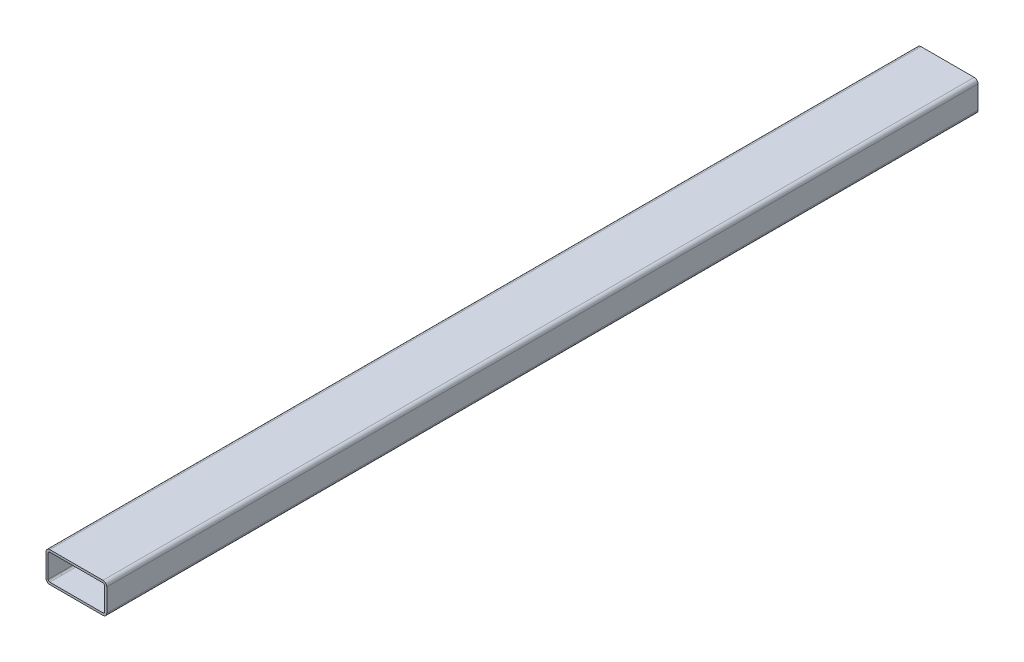
from build123d import *

# Parameters (mm, degrees)
BOSS_EXTRUDE1_DEPTH = 1146.7


with BuildPart() as part:
    # Sketch1 → Boss-Extrude1 (new body)
    with BuildSketch(Plane.XY):
        with BuildLine():
            Line((-35, -20), (35, -20))
            ThreePointArc((35, -20), (38.535533906, -18.535533906), (40, -15))
            Line((40, -15), (40, 15))
            ThreePointArc((40, 15), (38.535533906, 18.535533906), (35, 20))
            Line((35, 20), (-35, 20))
            ThreePointArc((-35, 20), (-38.535533906, 18.535533906), (-40, 15))
            Line((-40, 15), (-40, -15))
            ThreePointArc((-40, -15), (-38.535533906, -18.535533906), (-35, -20))
        make_face()
        with BuildLine():
            Line((-37.1, -15), (-37.1, 15))
            ThreePointArc((-37.1, 15), (-36.48492424, 16.48492424), (-35, 17.1))
            Line((-35, 17.1), (35, 17.1))
            ThreePointArc((35, 17.1), (36.48492424, 16.48492424), (37.1, 15))
            Line((37.1, 15), (37.1, -15))
            ThreePointArc((37.1, -15), (36.48492424, -16.48492424), (35, -17.1))
            Line((35, -17.1), (-35, -17.1))
            ThreePointArc((-35, -17.1), (-36.48492424, -16.48492424), (-37.1, -15))
        make_face(mode=Mode.SUBTRACT)
    extrude(amount=BOSS_EXTRUDE1_DEPTH)


solid = part.part
